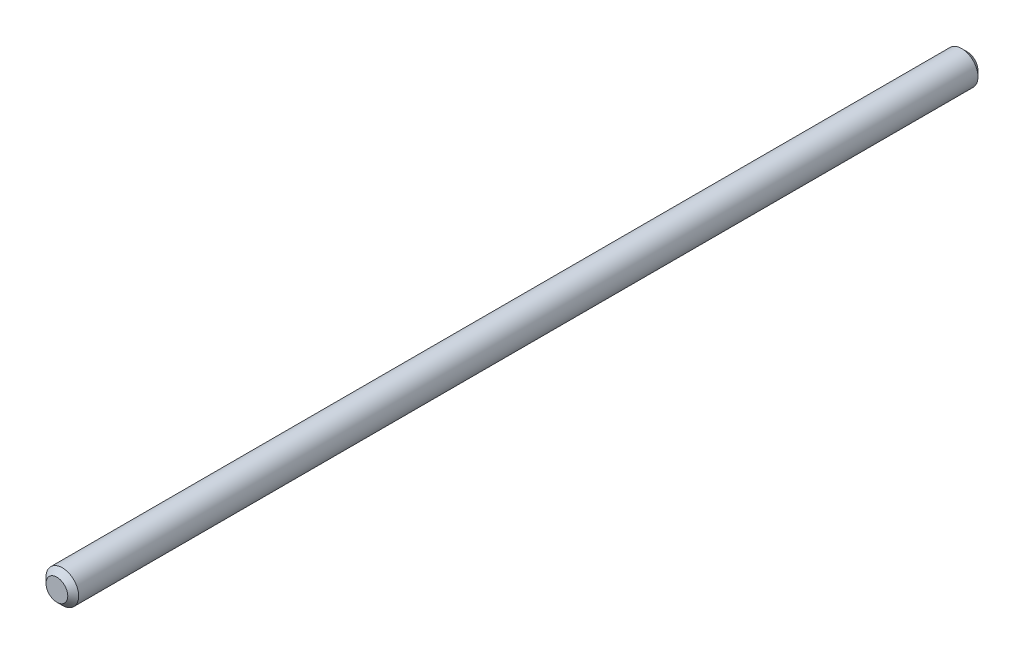
from build123d import *

# Parameters (mm, degrees)
ESQUISSE1_R          = 1.5
BASE_EXTRUSION_DEPTH = 83.6
CHANFREIN1_SIZE      = 0.5


with BuildPart() as part:
    # Esquisse1 → Base-Extrusion (new body)
    with BuildSketch(Plane.XY):
        Circle(ESQUISSE1_R)
    extrude(amount=BASE_EXTRUSION_DEPTH)

    # Chanfrein1
    chanfrein1_edges = [part.edges().sort_by_distance(p)[0] for p in [
        (-1.5, 0, 0),
        (-1.5, 0, 83.6),
    ]]
    chamfer(chanfrein1_edges, length=CHANFREIN1_SIZE)


solid = part.part
